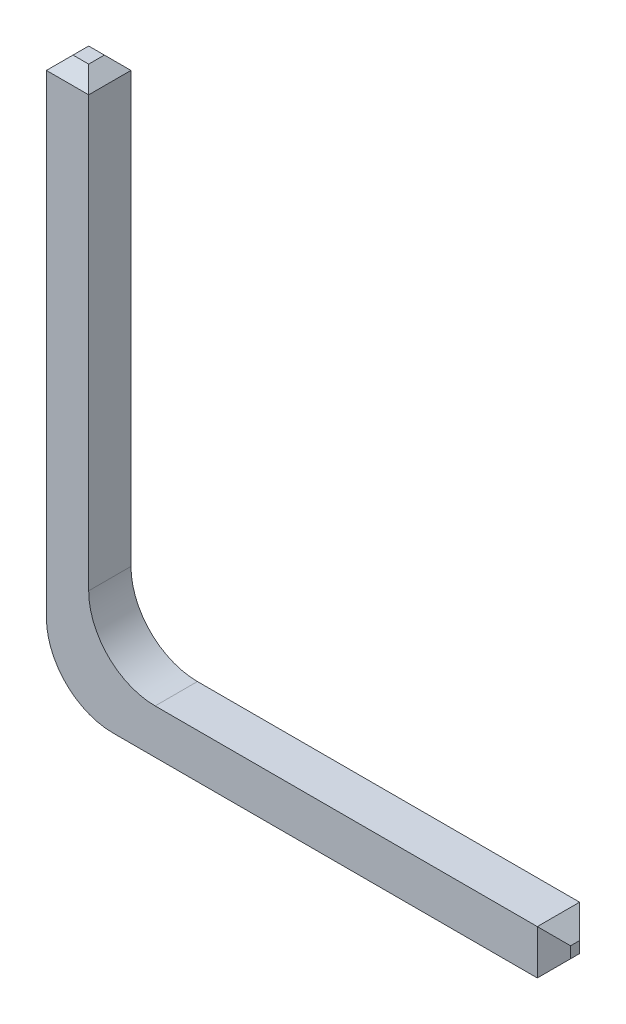
from build123d import *

# Parameters (mm, degrees)
PIN_DRAWING_W       = 0.636
PIN_DRAWING_H       = 0.636
PIN_DEPTH           = 11.54
CHAMFER2_SIZE       = 0.2
SKETCH1_W           = 7
SKETCH1_H           = 0.67
BOSS_EXTRUDE1_DEPTH = 0.636
CHAMFER3_SIZE       = 0.25
SKETCH2_W           = 0.636
SKETCH2_H           = 3.640361057
CUT_EXTRUDE1_DEPTH  = 0.636
FILLET1_R           = 1


with BuildPart() as part:
    # pin_drawing → pin (new body)
    with BuildSketch(Plane(origin=(0, 0, 0), x_dir=(1, 0, 0), z_dir=(0, 1, 0))):
        with Locations((0.318, -0.318)):
            Rectangle(PIN_DRAWING_W, PIN_DRAWING_H)
    extrude(amount=PIN_DEPTH)

    # Chamfer2
    chamfer2_edges = [part.edges().sort_by_distance(p)[0] for p in [
        (0.636, 11.54, 0.318),
        (0.318, 11.54, 0),
        (0, 11.54, 0.318),
        (0.318, 0, 0),
        (0.636, 0, 0.318),
        (0.318, 0, 0.636),
        (0, 0, 0.318),
        (0.318, 11.54, 0.636),
    ]]
    chamfer(chamfer2_edges, length=CHAMFER2_SIZE)

    # Sketch1 → Boss-Extrude1 (add)
    with BuildSketch(Plane(origin=(0, 0, 0), x_dir=(-1, 0, 0), z_dir=(0, 0, -1))):
        with Locations((-4.136, 3.542089627)):
            Rectangle(SKETCH1_W, SKETCH1_H)
    extrude(amount=-BOSS_EXTRUDE1_DEPTH)

    # Chamfer3
    chamfer3_edges = [part.edges().sort_by_distance(p)[0] for p in [
        (7.636, 3.877089627, 0.318),
        (7.636, 3.542089627, 0.636),
        (7.636, 3.542089627, 0),
        (7.636, 3.207089627, 0.318),
    ]]
    chamfer(chamfer3_edges, length=CHAMFER3_SIZE)

    # Sketch2 → Cut-Extrude1 (cut)
    with BuildSketch(Plane(origin=(0, 0, 0), x_dir=(-1, 0, 0), z_dir=(0, 0, -1))):
        with Locations((-0.318, 1.386909099)):
            Rectangle(SKETCH2_W, SKETCH2_H)
    extrude(amount=-CUT_EXTRUDE1_DEPTH, mode=Mode.SUBTRACT)

    # Fillet1
    fillet1_edges = [part.edges().sort_by_distance(p)[0] for p in [
        (0.636, 3.877089627, 0.318),
        (0, 3.207089627, 0.318),
    ]]
    fillet(fillet1_edges, radius=FILLET1_R)


solid = part.part
